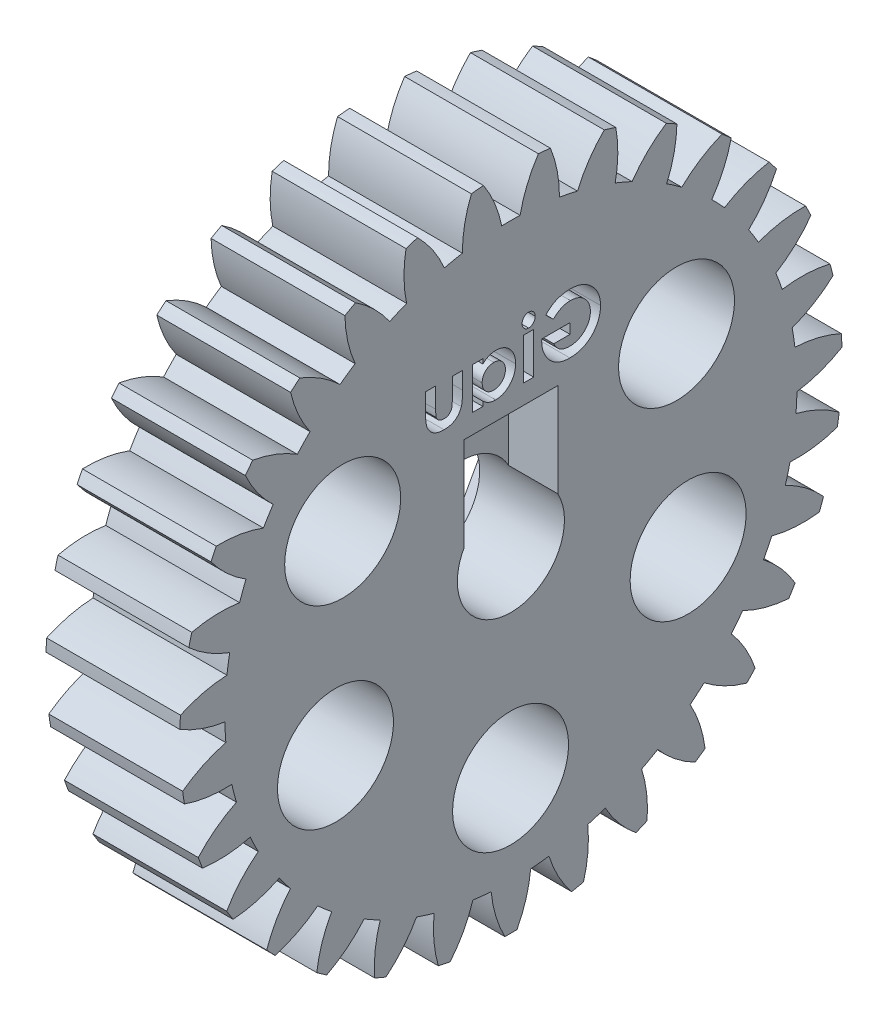
from build123d import *

# Parameters (mm, degrees)
BASPROSKE_W        = 15
BASPROSKE_H        = 37.125
TOOTHCUT_DEPTH     = 55.603399619
TEETHCUTS_COUNT    = 31
BORSKE_R           = 6
BORE_DEPTH         = 50.0000508
CUT_EXTRUDE1_DEPTH = 5.5
SKETCH1_W          = 1.13974359
SKETCH1_H          = 4.640384615
CUT_EXTRUDE3_DEPTH = 55.590168897
CUT_EXTRUDE5_DEPTH = 5.5
SKETCH10_R         = 6.5
CUT_EXTRUDE6_DEPTH = 55.590169061


with BuildPart() as part:
    # BasProSke → Base-Revolve (revolve)
    with BuildSketch(Plane(origin=(0, 0, 0), x_dir=(1, 0, 0), z_dir=(0, 1, 0)), mode=Mode.PRIVATE) as base_revolve_sk:
        with Locations((7.5, 18.5625)):
            Rectangle(BASPROSKE_W, BASPROSKE_H)
    revolve(base_revolve_sk.sketch.rotate(Axis((-10, 0, 0), (1, 0, 0)), 180), axis=Axis((-10, 0, 0), (1, 0, 0)))

    # TooCutSke → ToothCut (cut, through all)
    with BuildSketch(Plane(origin=(0, 0, 0), x_dir=(0, 0, -1), z_dir=(1, 0, 0))):
        with BuildLine():
            ThreePointArc((1.030914544, 32.044921555), (0, 32.0615), (-1.030914544, 32.044921555))
            ThreePointArc((-1.030914544, 32.044921555), (-1.820854389, 34.633687107), (-3.095833874, 37.021183568))
            ThreePointArc((-3.095833874, 37.021183568), (0, 37.1504), (3.095833874, 37.021183568))
            ThreePointArc((3.095833874, 37.021183568), (1.820854389, 34.633687107), (1.030914544, 32.044921555))
        make_face()
    toothcut = extrude(amount=TOOTHCUT_DEPTH, mode=Mode.SUBTRACT)

    # TeethCuts: ToothCut ×31 about axis
    teethcuts_axis = Axis((0, 0, 0), (1, 0, 0))
    for i in range(1, TEETHCUTS_COUNT):
        add(toothcut.rotate(teethcuts_axis, i * 360 / TEETHCUTS_COUNT), mode=Mode.SUBTRACT)

    # BorSke → Bore (cut, symmetric)
    with BuildSketch(Plane(origin=(0, 0, 0), x_dir=(0, 0, -1), z_dir=(1, 0, 0))):
        with Locations(Location((0, 0, 0), (0, 0, 180))):
            Circle(BORSKE_R)
    extrude(amount=BORE_DEPTH, both=True, mode=Mode.SUBTRACT)

    # Sketch2 → Cut-Extrude1 (cut)
    with BuildSketch(Plane(origin=(15, 0, 0), x_dir=(0, 0, -1), z_dir=(1, 0, 0))):
        with BuildLine():
            Line((-5.25, 2.90473751), (-5.25, 13.40473751))
            Line((-5.25, 13.40473751), (5.25, 13.40473751))
            Line((5.25, 13.40473751), (5.25, 2.90473751))
            ThreePointArc((5.25, 2.90473751), (0, -6), (-5.25, 2.90473751))
        make_face()
    extrude(amount=-CUT_EXTRUDE1_DEPTH, mode=Mode.SUBTRACT)

    # Sketch1 → Cut-Extrude3 (cut, through all)
    with BuildSketch(Plane.ZY):
        with BuildLine():
            Line((-3.901072378, 20.915399906), (-4.763512282, 20.089849025))
            add(Edge.make_bspline(
                [(-4.763512282, 20.089849025), (-4.831793154, 20.158211709), (-4.965771498, 20.292350583), (-5.184876319, 20.466941545), (-5.411802417, 20.615378378), (-5.647296698, 20.737433525), (-5.891687205, 20.832110109), (-6.144491652, 20.899835299), (-6.40612132, 20.940004257), (-6.583232926, 20.945627774), (-6.672837202, 20.948472823)],
                knots=[0, 0, 0, 0, 1.075575784, 2.110457258, 3.113929901, 4.09197124, 5.059417775, 6.02750972, 7.002078037, 8, 8, 8, 8], degree=3))
            add(Edge.make_bspline(
                [(-6.672837202, 20.948472823), (-6.750521369, 20.94647931), (-6.903061041, 20.942564873), (-7.127203397, 20.912838903), (-7.341385149, 20.863183008), (-7.546618179, 20.794393056), (-7.741649468, 20.704875588), (-7.927609065, 20.596012199), (-8.103352571, 20.466970077), (-8.267496134, 20.32019541), (-8.416949377, 20.159947108), (-8.547429949, 19.98842476), (-8.658571365, 19.808825398), (-8.750063417, 19.620230164), (-8.819678919, 19.422928515), (-8.869375278, 19.217063681), (-8.900920108, 19.003233934), (-8.90464461, 18.857357066), (-8.906531112, 18.783468816)],
                knots=[0, 0, 0, 0, 1.075001177, 2.110859044, 3.123021556, 4.114053297, 5.101481495, 6.087880186, 7.091499647, 8.114004866, 9.131394192, 10.11971144, 11.092043119, 12.050101265, 13.015322563, 13.981809771, 14.977764287, 16, 16, 16, 16], degree=3))
            add(Edge.make_bspline(
                [(-8.906531112, 18.783468816), (-8.904771473, 18.707023195), (-8.901304745, 18.556414856), (-8.868002897, 18.335390644), (-8.816695668, 18.122749424), (-8.741595564, 17.920068947), (-8.64917008, 17.724572771), (-8.531959338, 17.540047844), (-8.395279884, 17.363676269), (-8.239375945, 17.198528775), (-8.06979272, 17.04630253), (-7.88612857, 16.914988253), (-7.693971684, 16.801692377), (-7.490220642, 16.711965705), (-7.278411958, 16.639925018), (-7.056397284, 16.589130151), (-6.824676543, 16.557967676), (-6.666575571, 16.55422062), (-6.586338804, 16.552318977)],
                knots=[0, 0, 0, 0, 1.022067601, 2.013613092, 2.983553406, 3.943623673, 4.90013463, 5.87121881, 6.861774014, 7.881098904, 8.905697761, 9.905387765, 10.89678721, 11.884561068, 12.87834324, 13.885584958, 14.926927371, 16, 16, 16, 16], degree=3))
            add(Edge.make_bspline(
                [(-6.586338804, 16.552318977), (-6.534147759, 16.552789887), (-6.431685124, 16.55371439), (-6.2813899, 16.568721668), (-6.137443175, 16.590176316), (-5.999287482, 16.618579722), (-5.868317824, 16.658775638), (-5.742720837, 16.705779813), (-5.623232407, 16.761254111), (-5.510500388, 16.8271125), (-5.402847002, 16.900931703), (-5.301279905, 16.98539657), (-5.20401749, 17.078602727), (-5.112196256, 17.181688821), (-5.027370304, 17.295576563), (-4.946822027, 17.418173113), (-4.871473687, 17.550695168), (-4.826952342, 17.644275531), (-4.80421741, 17.692062566)],
                knots=[0, 0, 0, 0, 1.109579412, 2.178351274, 3.208885622, 4.204702371, 5.174744997, 6.119429583, 7.05542196, 7.97267548, 8.893247984, 9.828544973, 10.778894627, 11.756245826, 12.760884819, 13.796418446, 14.874735809, 16, 16, 16, 16], degree=3))
            Line((-4.80421741, 17.692062566), (-6.627043932, 17.692062566))
            Line((-6.627043932, 17.692062566), (-6.627043932, 18.831806156))
            Line((-6.627043932, 18.831806156), (-3.460948179, 18.831806156))
            Line((-3.460948179, 18.831806156), (-3.452043932, 18.560862647))
            add(Edge.make_bspline(
                [(-3.452043932, 18.560862647), (-3.453188062, 18.491277479), (-3.455474279, 18.352231324), (-3.476367905, 18.145215287), (-3.510977879, 17.940944888), (-3.558293027, 17.739625291), (-3.617590875, 17.540268953), (-3.693214195, 17.344784875), (-3.781768639, 17.151847349), (-3.880987612, 16.962276212), (-3.99248119, 16.780377551), (-4.112520397, 16.608143531), (-4.239393994, 16.445872252), (-4.375861427, 16.29582456), (-4.519797676, 16.156739987), (-4.671486079, 16.029153609), (-4.831463151, 15.912957472), (-4.99888143, 15.807169983), (-5.174694524, 15.714453491), (-5.357935813, 15.633802443), (-5.548328627, 15.565307211), (-5.746364517, 15.509156021), (-5.951653796, 15.465830911), (-6.164200863, 15.436122826), (-6.384122451, 15.415935849), (-6.533290612, 15.413709083), (-6.609235439, 15.412575387)],
                knots=[0, 0, 0, 0, 1.006889344, 2.011981806, 3.007738725, 4.003571281, 5.003404394, 6.015442001, 7.03424805, 8.074616296, 9.110249922, 10.119753985, 11.111721717, 12.089233633, 13.052717867, 14.006597561, 14.955430184, 15.912305663, 16.870361111, 17.829300583, 18.807640451, 19.796414044, 20.806216501, 21.841577364, 22.90109906, 24, 24, 24, 24], degree=3))
            add(Edge.make_bspline(
                [(-6.609235439, 15.412575387), (-6.69026342, 15.413694933), (-6.850885045, 15.415914206), (-7.088385646, 15.436699215), (-7.318996207, 15.471003529), (-7.542774247, 15.518479528), (-7.760239334, 15.577567202), (-7.971017829, 15.651736209), (-8.174678634, 15.739962588), (-8.371831617, 15.839910071), (-8.559956948, 15.953259223), (-8.738633008, 16.078022453), (-8.906884549, 16.215002306), (-9.066434989, 16.361905709), (-9.213556612, 16.522343563), (-9.353732067, 16.691115297), (-9.480170333, 16.874410786), (-9.598307879, 17.066287537), (-9.703262219, 17.266665142), (-9.795046298, 17.471837515), (-9.873319709, 17.680616707), (-9.935040185, 17.893974863), (-9.985151431, 18.110424272), (-10.021006969, 18.330906223), (-10.041256266, 18.555393115), (-10.044594463, 18.706259935), (-10.046274702, 18.782196781)],
                knots=[0, 0, 0, 0, 1.084149091, 2.14910686, 3.187506334, 4.202448172, 5.208724393, 6.201130722, 7.189831603, 8.176984443, 9.156919086, 10.126598231, 11.090766514, 12.05840148, 13.026036446, 14.001772938, 14.991905635, 16.003017641, 17.015720547, 18.016462227, 19.009322657, 19.99686681, 20.986544154, 21.980959929, 22.983742515, 24, 24, 24, 24], degree=3))
            add(Edge.make_bspline(
                [(-10.046274702, 18.782196781), (-10.044024504, 18.885790867), (-10.03958103, 19.090358472), (-9.998427723, 19.391687852), (-9.934275849, 19.683193961), (-9.84221145, 19.963815153), (-9.724071086, 20.233937987), (-9.581528322, 20.494196589), (-9.41148682, 20.744314328), (-9.279863019, 20.899171946), (-9.213091609, 20.977729634)],
                knots=[0, 0, 0, 0, 1.034044851, 2.041932006, 3.031217818, 4.011390712, 4.986069675, 5.97149666, 6.970960976, 8, 8, 8, 8], degree=3))
            add(Edge.make_bspline(
                [(-9.213091609, 20.977729634), (-9.171633893, 21.023177637), (-9.08934095, 21.113391241), (-8.95779583, 21.238744878), (-8.82291469, 21.356581935), (-8.682829403, 21.46440375), (-8.538276372, 21.564570595), (-8.388839548, 21.655204762), (-8.235302842, 21.739192092), (-8.076468854, 21.812243873), (-7.913169101, 21.877740888), (-7.744680355, 21.933160572), (-7.572264561, 21.982249239), (-7.394394973, 22.019593125), (-7.212868496, 22.050690264), (-7.026396597, 22.071533194), (-6.835487421, 22.086809579), (-6.706366056, 22.087743759), (-6.64103632, 22.088216413)],
                knots=[0, 0, 0, 0, 1.020590567, 2.025856924, 3.013483481, 3.991664875, 4.957826714, 5.930500614, 6.890802512, 7.860442893, 8.829981142, 9.809047939, 10.802672283, 11.803273349, 12.823572789, 13.857849586, 14.916166035, 16, 16, 16, 16], degree=3))
            add(Edge.make_bspline(
                [(-6.64103632, 22.088216413), (-6.572745536, 22.087163251), (-6.436871951, 22.085067847), (-6.234850431, 22.070569016), (-6.035636135, 22.048200737), (-5.840068573, 22.014647042), (-5.647491418, 21.973268352), (-5.458901495, 21.920252009), (-5.27306849, 21.860015893), (-5.152091907, 21.811991211), (-5.091697378, 21.788016092)],
                knots=[0, 0, 0, 0, 1.03180557, 2.052914215, 3.058998889, 4.059601663, 5.049854447, 6.033765722, 7.018406786, 8, 8, 8, 8], degree=3))
            add(Edge.make_bspline(
                [(-5.091697378, 21.788016092), (-5.040882853, 21.765858766), (-4.937527514, 21.720791378), (-4.787158235, 21.638338479), (-4.636421563, 21.546929976), (-4.486944023, 21.443223764), (-4.338953377, 21.32741382), (-4.190904445, 21.201329344), (-4.044308563, 21.063500117), (-3.94943611, 20.965405977), (-3.901072378, 20.915399906)],
                knots=[0, 0, 0, 0, 0.894392155, 1.819168899, 2.76525314, 3.739198753, 4.75366411, 5.797420238, 6.877176959, 8, 8, 8, 8], degree=3))
        make_face()
        with BuildLine():
            add(Edge.make_bspline(
                [(-1.989203387, 22.169626669), (-1.940080447, 22.167216512), (-1.84362282, 22.162483935), (-1.705434144, 22.116351845), (-1.578604945, 22.043948906), (-1.466484416, 21.94461035), (-1.373233044, 21.825981943), (-1.301985532, 21.693169556), (-1.262296512, 21.546017707), (-1.256784294, 21.44436675), (-1.253967009, 21.392413127)],
                knots=[0, 0, 0, 0, 0.989868614, 1.943702388, 2.910836514, 3.924849579, 4.949916355, 5.946401046, 6.950409252, 8, 8, 8, 8], degree=3))
            add(Edge.make_bspline(
                [(-1.253967009, 21.392413127), (-1.256683496, 21.340842374), (-1.261976701, 21.240354307), (-1.302899, 21.095200113), (-1.371286883, 20.962452233), (-1.465293533, 20.845585679), (-1.576198529, 20.747847028), (-1.700256413, 20.674129658), (-1.837120841, 20.630563885), (-1.932081737, 20.625435692), (-1.980299141, 20.622831797)],
                knots=[0, 0, 0, 0, 1.05296456, 2.051751585, 3.055639087, 4.085634717, 5.099016424, 6.062201612, 7.016062274, 8, 8, 8, 8], degree=3))
            add(Edge.make_bspline(
                [(-1.980299141, 20.622831797), (-2.029850884, 20.625233339), (-2.127147688, 20.62994886), (-2.266469796, 20.67618889), (-2.394990573, 20.748021608), (-2.506624724, 20.849389805), (-2.600944032, 20.968861156), (-2.669079424, 21.104765531), (-2.711699797, 21.2529236), (-2.716758798, 21.356080078), (-2.719351625, 21.408949586)],
                knots=[0, 0, 0, 0, 0.989065327, 1.942068821, 2.907541208, 3.917690034, 4.939857478, 5.938239964, 6.943311734, 8, 8, 8, 8], degree=3))
            add(Edge.make_bspline(
                [(-2.719351625, 21.408949586), (-2.71652992, 21.459644636), (-2.710987089, 21.559227745), (-2.671060327, 21.703107976), (-2.601446519, 21.83368758), (-2.508866846, 21.950144382), (-2.397731112, 22.047629901), (-2.270978051, 22.117833915), (-2.133719389, 22.162060619), (-2.037872787, 22.167078611), (-1.989203387, 22.169626669)],
                knots=[0, 0, 0, 0, 1.038616768, 2.040212704, 3.031499824, 4.052181184, 5.074969369, 6.039807101, 7.004644834, 8, 8, 8, 8], degree=3))
        make_face()
        with Locations((-1.986659317, 17.895588208)):
            Rectangle(SKETCH1_W, SKETCH1_H)
        with BuildLine():
            Line((3.142186837, 20.215780515), (4.281930427, 20.215780515))
            Line((4.281930427, 20.215780515), (4.281930427, 15.5753959))
            Line((4.281930427, 15.5753959), (3.142186837, 15.5753959))
            Line((3.142186837, 15.5753959), (3.142186837, 16.081665932))
            add(Edge.make_bspline(
                [(3.142186837, 16.081665932), (3.085712962, 16.032386147), (2.976108323, 15.936743818), (2.803406878, 15.812645463), (2.63020078, 15.710280359), (2.455657768, 15.628752137), (2.27709519, 15.568551935), (2.093227466, 15.524965584), (1.901406705, 15.499261646), (1.771009595, 15.49576263), (1.704786997, 15.493985643)],
                knots=[0, 0, 0, 0, 1.129196829, 2.191548051, 3.199897424, 4.157751732, 5.089409408, 6.034969131, 7.002052659, 8, 8, 8, 8], degree=3))
            add(Edge.make_bspline(
                [(1.704786997, 15.493985643), (1.630449187, 15.495658012), (1.483553461, 15.498962706), (1.268000291, 15.533749946), (1.059862276, 15.586999571), (0.859308367, 15.662354446), (0.666703451, 15.759999592), (0.480573518, 15.877387309), (0.304109403, 16.018638609), (0.135842101, 16.177641908), (-0.018222431, 16.352546668), (-0.1529071, 16.540925235), (-0.266436266, 16.740105876), (-0.359444637, 16.949428213), (-0.432607731, 17.168738618), (-0.484762548, 17.398732675), (-0.51553395, 17.639492527), (-0.519342583, 17.80348871), (-0.521274702, 17.886683961)],
                knots=[0, 0, 0, 0, 0.980476535, 1.937477201, 2.874147792, 3.812856188, 4.758993464, 5.720109578, 6.712210464, 7.737600662, 8.772720504, 9.783789959, 10.789002326, 11.793715968, 12.802552247, 13.835794126, 14.902098527, 16, 16, 16, 16], degree=3))
            add(Edge.make_bspline(
                [(-0.521274702, 17.886683961), (-0.519246935, 17.972832752), (-0.515269246, 18.141823206), (-0.486172688, 18.389808661), (-0.434980323, 18.625505402), (-0.365175855, 18.849239903), (-0.275384526, 19.061050815), (-0.166024688, 19.261285154), (-0.035608602, 19.449419538), (0.114672818, 19.622251789), (0.276939841, 19.780660894), (0.450536869, 19.918568583), (0.632749224, 20.035727582), (0.82377054, 20.13137479), (1.023573536, 20.205286112), (1.231369395, 20.259321324), (1.448080583, 20.291744349), (1.595706, 20.29536022), (1.670442045, 20.297190772)],
                knots=[0, 0, 0, 0, 1.136281865, 2.228943489, 3.287578264, 4.313574083, 5.316051562, 6.317280042, 7.318008486, 8.329309503, 9.333984563, 10.305318864, 11.248632312, 12.186624717, 13.117503092, 14.05354244, 15.014596925, 16, 16, 16, 16], degree=3))
            add(Edge.make_bspline(
                [(1.670442045, 20.297190772), (1.739671839, 20.295752508), (1.876652647, 20.292906703), (2.077994699, 20.262006707), (2.273267449, 20.215272658), (2.461405676, 20.14868505), (2.643952552, 20.064604649), (2.817768155, 19.959245638), (2.986654857, 19.837036211), (3.0897023, 19.74158806), (3.142186837, 19.692974025)],
                knots=[0, 0, 0, 0, 1.017011718, 2.012299608, 2.98747302, 3.965332399, 4.941441765, 5.936729654, 6.94912688, 8, 8, 8, 8], degree=3))
            Line((3.142186837, 19.692974025), (3.142186837, 20.215780515))
        make_face()
        with BuildLine():
            add(Edge.make_bspline(
                [(1.909584673, 19.238857438), (1.864169251, 19.237463936), (1.775157989, 19.234732764), (1.644254746, 19.218304569), (1.519150516, 19.189357357), (1.400737531, 19.146594069), (1.287251003, 19.094502153), (1.180414242, 19.029257886), (1.079345494, 18.952140548), (0.984639153, 18.86501715), (0.898300369, 18.769252606), (0.823871298, 18.66475274), (0.760618612, 18.554333229), (0.707123279, 18.43766208), (0.668832758, 18.313358713), (0.638506681, 18.183041336), (0.62276941, 18.045645323), (0.619916739, 17.952014193), (0.618468888, 17.904492454)],
                knots=[0, 0, 0, 0, 1.04836806, 2.054732945, 3.03993516, 4.00574415, 4.955904794, 5.917688631, 6.888591924, 7.88601754, 8.884115178, 9.859153345, 10.841239365, 11.818093293, 12.814750328, 13.83810466, 14.90274714, 16, 16, 16, 16], degree=3))
            add(Edge.make_bspline(
                [(0.618468888, 17.904492454), (0.619894622, 17.856539666), (0.622704015, 17.762049252), (0.638761137, 17.623494255), (0.667995957, 17.491273247), (0.710648456, 17.366455146), (0.762737052, 17.247355743), (0.826140586, 17.134524692), (0.904020724, 17.029956988), (0.990435193, 16.931178208), (1.08708442, 16.842972591), (1.188725056, 16.764654101), (1.296745433, 16.699125071), (1.409973606, 16.646164094), (1.528028443, 16.60300535), (1.652389994, 16.574421946), (1.781839982, 16.556149116), (1.870089456, 16.553604506), (1.914672814, 16.552318977)],
                knots=[0, 0, 0, 0, 1.099136573, 2.165835871, 3.191374663, 4.196217796, 5.183857741, 6.167377911, 7.154730987, 8.166690795, 9.170734848, 10.148332609, 11.103258353, 12.059567475, 13.009337315, 13.978056681, 14.978520572, 16, 16, 16, 16], degree=3))
            add(Edge.make_bspline(
                [(1.914672814, 16.552318977), (1.960934152, 16.553720291), (2.051631522, 16.556467629), (2.184670385, 16.572745898), (2.311455214, 16.601799247), (2.431458517, 16.644807365), (2.546513229, 16.696525364), (2.655581085, 16.760494709), (2.757478535, 16.837435083), (2.852721643, 16.92534608), (2.93999359, 17.021892599), (3.015451956, 17.127762814), (3.081178954, 17.239570707), (3.132870213, 17.359959823), (3.173920322, 17.486823914), (3.203372829, 17.620950326), (3.219393285, 17.762483664), (3.222178107, 17.859085682), (3.223597093, 17.90830856)],
                knots=[0, 0, 0, 0, 1.050008698, 2.058587853, 3.036635738, 3.995319155, 4.947022481, 5.895997462, 6.858296291, 7.838991643, 8.833936038, 9.806048392, 10.784806122, 11.771666913, 12.772873988, 13.80724452, 14.882696879, 16, 16, 16, 16], degree=3))
            add(Edge.make_bspline(
                [(3.223597093, 17.90830856), (3.222195739, 17.956684828), (3.219458487, 18.051177733), (3.203303737, 18.189755921), (3.173642134, 18.321248703), (3.133436904, 18.445897779), (3.080826041, 18.563418141), (3.015049313, 18.672506768), (2.940418682, 18.776943172), (2.852180508, 18.870881435), (2.757453354, 18.958155888), (2.654057337, 19.03276953), (2.545249992, 19.097073637), (2.430362806, 19.149869788), (2.308331974, 19.188571369), (2.181330478, 19.218536587), (2.047376831, 19.234722904), (1.95626493, 19.23745677), (1.909584673, 19.238857438)],
                knots=[0, 0, 0, 0, 1.106611376, 2.161533483, 3.185006901, 4.184773755, 5.152708835, 6.122342771, 7.094156588, 8.082475533, 9.064254463, 10.03606828, 10.992420271, 11.951521816, 12.920622147, 13.915721683, 14.932141191, 16, 16, 16, 16], degree=3))
        make_face(mode=Mode.SUBTRACT)
        with BuildLine():
            Line((5.421674016, 20.215780515), (6.561417606, 20.215780515))
            Line((6.561417606, 20.215780515), (6.561417606, 17.988446781))
            add(Edge.make_bspline(
                [(6.561417606, 17.988446781), (6.561518816, 17.936288001), (6.561713062, 17.836182566), (6.567118305, 17.692411562), (6.574702928, 17.560939562), (6.584168026, 17.441611537), (6.59829529, 17.33471451), (6.614604621, 17.240452551), (6.633094141, 17.158146491), (6.663160435, 17.066405414), (6.710199695, 16.96601245), (6.781237305, 16.859433529), (6.867284569, 16.767273925), (6.967178933, 16.68871577), (7.081940561, 16.62681022), (7.209988341, 16.584857772), (7.34971117, 16.556661366), (7.447027911, 16.553804588), (7.497635555, 16.552318977)],
                knots=[0, 0, 0, 0, 1.267339619, 2.432334223, 3.495366327, 4.467371443, 5.340232306, 6.114347373, 6.791623365, 7.387877112, 8.457231658, 9.474542289, 10.487879852, 11.508108106, 12.54995813, 13.638205937, 14.771795776, 16, 16, 16, 16], degree=3))
            add(Edge.make_bspline(
                [(7.497635555, 16.552318977), (7.548198289, 16.554014591), (7.645766707, 16.557286536), (7.786419166, 16.582802027), (7.914768548, 16.626523672), (8.032133084, 16.685826923), (8.135051687, 16.765194223), (8.224658705, 16.859765992), (8.300105712, 16.971067788), (8.336361478, 17.054095739), (8.354987318, 17.096750066)],
                knots=[0, 0, 0, 0, 1.116871431, 2.155171802, 3.144773418, 4.104381479, 5.046960687, 6.001340237, 6.973219418, 8, 8, 8, 8], degree=3))
            add(Edge.make_bspline(
                [(8.354987318, 17.096750066), (8.361822375, 17.115697501), (8.376909976, 17.157521778), (8.390338239, 17.229674411), (8.40479105, 17.31476676), (8.416223736, 17.414532934), (8.422692753, 17.528355072), (8.429623642, 17.65637663), (8.433155748, 17.798470105), (8.433613796, 17.898130922), (8.433853504, 17.950285723)],
                knots=[0, 0, 0, 0, 0.56094539, 1.238222264, 2.041156151, 2.969685991, 4.036367568, 5.220421584, 6.545382566, 8, 8, 8, 8], degree=3))
            Line((8.433853504, 17.950285723), (8.433853504, 20.215780515))
            Line((8.433853504, 20.215780515), (9.573597093, 20.215780515))
            Line((9.573597093, 20.215780515), (9.573597093, 18.265750467))
            add(Edge.make_bspline(
                [(9.573597093, 18.265750467), (9.573399748, 18.169063842), (9.573021377, 17.983686318), (9.562177495, 17.717768283), (9.54721171, 17.475995714), (9.527938657, 17.257702935), (9.50016857, 17.062799352), (9.466079308, 16.89174202), (9.4283657, 16.743400568), (9.393780917, 16.655507233), (9.377703664, 16.614648704)],
                knots=[0, 0, 0, 0, 1.388070971, 2.661352173, 3.82033814, 4.865898334, 5.806910977, 6.645039373, 7.370126333, 8, 8, 8, 8], degree=3))
            add(Edge.make_bspline(
                [(9.377703664, 16.614648704), (9.357096767, 16.570672304), (9.316420522, 16.483866668), (9.245839676, 16.360448278), (9.169749571, 16.243519131), (9.08452981, 16.135831625), (8.991919993, 16.036291288), (8.894537908, 15.942635329), (8.787997972, 15.858677557), (8.67506316, 15.782257503), (8.554157622, 15.714420065), (8.426109473, 15.654304605), (8.28953495, 15.605380929), (8.145618316, 15.563911213), (7.993696208, 15.532985113), (7.834074657, 15.509560951), (7.666578595, 15.497455255), (7.552349383, 15.49516113), (7.493819449, 15.493985643)],
                knots=[0, 0, 0, 0, 0.997311338, 1.968606903, 2.91805772, 3.860812155, 4.785445165, 5.709667791, 6.633356648, 7.568312411, 8.508286151, 9.478643871, 10.470653671, 11.485274776, 12.552984541, 13.653035246, 14.797438149, 16, 16, 16, 16], degree=3))
            add(Edge.make_bspline(
                [(7.493819449, 15.493985643), (7.430590673, 15.494739164), (7.3068734, 15.496213547), (7.126124191, 15.514268966), (6.953867766, 15.537630332), (6.792027356, 15.577348934), (6.638342784, 15.623364923), (6.494578436, 15.682093564), (6.360146855, 15.751141805), (6.234783529, 15.830100291), (6.11946073, 15.919692593), (6.011614126, 16.016045994), (5.91472547, 16.122994091), (5.825631741, 16.237234285), (5.745327275, 16.359817984), (5.673772215, 16.490309318), (5.610905949, 16.629301827), (5.577363677, 16.726715729), (5.560325859, 16.776197182)],
                knots=[0, 0, 0, 0, 1.211240017, 2.369985978, 3.478996442, 4.539426614, 5.559871561, 6.551301256, 7.510778031, 8.453136967, 9.386094087, 10.30661716, 11.221130616, 12.147659962, 13.080758632, 14.026335491, 14.997475882, 16, 16, 16, 16], degree=3))
            add(Edge.make_bspline(
                [(5.560325859, 16.776197182), (5.548702105, 16.814626372), (5.523661827, 16.897411806), (5.496625999, 17.034991535), (5.475001761, 17.193559875), (5.453966386, 17.373272802), (5.439291724, 17.574431604), (5.42970019, 17.796716814), (5.423219488, 18.04056311), (5.42220435, 18.210200439), (5.421674016, 18.298823384)],
                knots=[0, 0, 0, 0, 0.627914866, 1.352675004, 2.190563461, 3.132055958, 4.183353232, 5.345633452, 6.613289997, 8, 8, 8, 8], degree=3))
            Line((5.421674016, 18.298823384), (5.421674016, 20.215780515))
        make_face()
    extrude(amount=-CUT_EXTRUDE3_DEPTH, mode=Mode.SUBTRACT)


with BuildPart() as cut_extrude3_piece_1:
    # of the separate pieces the step leaves, piece 1, a body of its own (cut_extrude3_pieces)
    add(part.part.solids().sort_by_distance((0, 36.997034521, -3.079782727))[0])

    # Sketch8 → Cut-Extrude5 (cut)
    with BuildSketch(Plane.ZY):
        Polygon((13.854005973, -0.294685119), (7.150361146, 11.832191891), (-6.703644827, 12.090103679), (-13.854005973, 0.221138455), (-7.150361146, -11.905738556), (6.703644827, -12.163650343), align=None)
    extrude(amount=-CUT_EXTRUDE5_DEPTH, mode=Mode.SUBTRACT)

    # Sketch10 → Cut-Extrude6 (cut, through all)
    with BuildSketch(Plane.ZY):
        with Locations((-19.863387595, -9.577864097)):
            Circle(SKETCH10_R)
        with Locations((0.040469936, -22.041338682)):
            Circle(SKETCH10_R)
        with Locations((19.66580652, -10.026222395)):
            Circle(SKETCH10_R)
        with Locations((18.858194519, 11.322709237)):
            Circle(SKETCH10_R)
        with Locations((-18.562453348, 11.784144122)):
            Circle(SKETCH10_R)
    extrude(amount=-CUT_EXTRUDE6_DEPTH, mode=Mode.SUBTRACT)


with BuildPart() as cut_extrude3_piece_2:
    # of the separate pieces the step leaves, piece 2, a body of its own (cut_extrude3_pieces)
    add(part.part.solids().sort_by_distance((0, 17.90830856, 3.223597093))[0])


solid = Compound([cut_extrude3_piece_1.part, cut_extrude3_piece_2.part])
